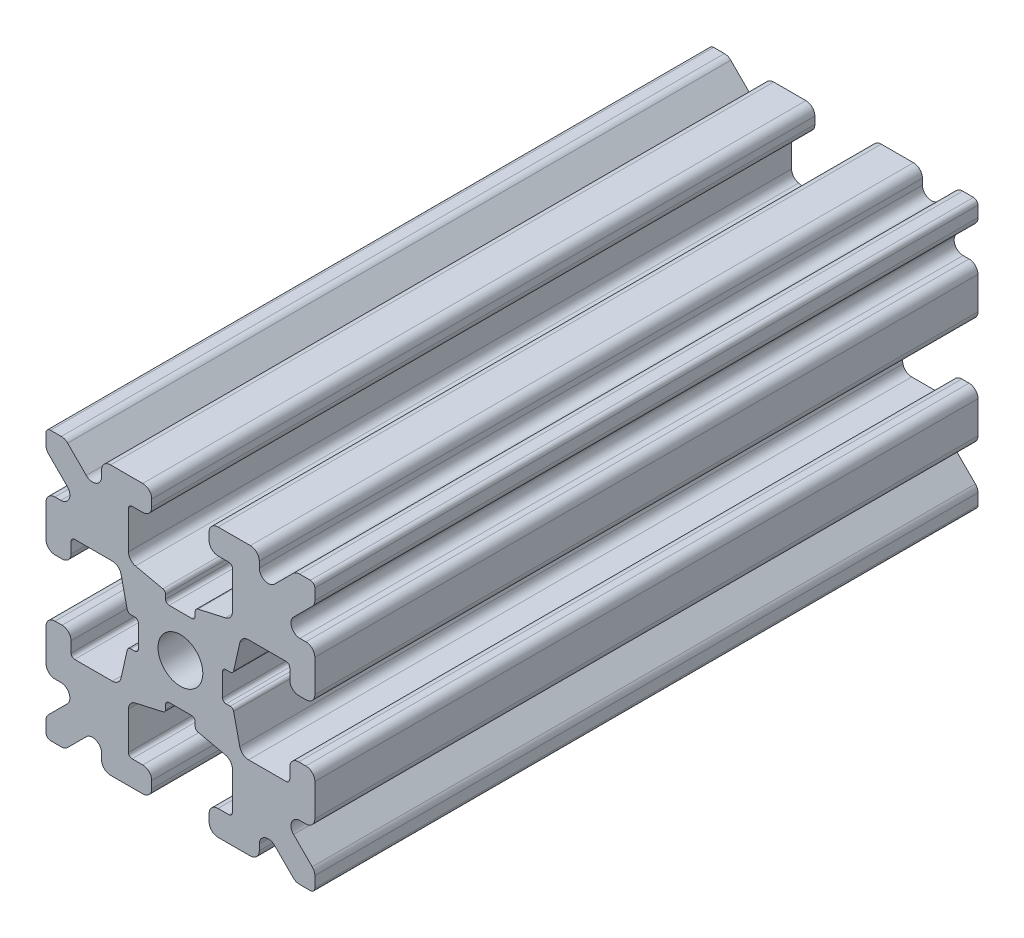
from build123d import *

# Parameters (mm, degrees)
SKETCH1_W           = 15
SKETCH1_H           = 15
SKETCH1_R           = 1.25
BOSS_EXTRUDE1_DEPTH = 18.5
FILLET1_R           = 0.25
CUT_EXTRUDE1_DEPTH  = 38
CUT_EXTRUDE3_DEPTH  = 38
FILLET3_R           = 0.5
FILLET4_R           = 0.5
FILLET5_R           = 3
FILLET6_R           = 0.2
CUT_EXTRUDE4_DEPTH  = 38
FILLET8_R           = 0.5
SKETCH6_W           = 5.1529354
SKETCH6_H           = 1.651
SKETCH6_W_2         = 1.651
SKETCH6_H_2         = 5.1529354
CUT_EXTRUDE5_DEPTH  = 38
FILLET10_R          = 0.2


with BuildPart() as part:
    # Sketch1 → Boss-Extrude1 (new body, symmetric)
    with BuildSketch(Plane.XY):
        Rectangle(SKETCH1_W, SKETCH1_H)
        Circle(SKETCH1_R, mode=Mode.SUBTRACT)
    extrude(amount=BOSS_EXTRUDE1_DEPTH, both=True)

    # Fillet1
    fillet1_edges = [part.edges().sort_by_distance(p)[0] for p in [
        (7.5, -7.5, 0),
        (-7.5, -7.5, 0),
        (-7.5, 7.5, 0),
        (7.5, 7.5, 0),
    ]]
    fillet(fillet1_edges, radius=FILLET1_R)

    # Sketch2 → Cut-Extrude1 (cut, through all)
    with BuildSketch(Plane.XY.offset(18.5)):
        Polygon((-7.5, 1.6), (-6.1, 1.6), (-6.1, 2.9), (-3.4, 2.9), (-3.4, -2.9), (-6.1, -2.9), (-6.1, -1.6), (-7.5, -1.6), align=None)
        Polygon((2.9, 6.1), (1.6, 6.1), (1.6, 7.5), (-1.6, 7.5), (-1.6, 6.1), (-2.9, 6.1), (-2.9, 3.4), (2.9, 3.4), align=None)
        Polygon((-1.6, -7.5), (-1.6, -6.1), (-2.9, -6.1), (-2.9, -3.4), (2.9, -3.4), (2.9, -6.1), (1.6, -6.1), (1.6, -7.5), align=None)
        Polygon((6.1, -2.9), (6.1, -1.6), (7.5, -1.6), (7.5, 1.6), (6.1, 1.6), (6.1, 2.9), (3.4, 2.9), (3.4, -2.9), align=None)
    extrude(amount=-CUT_EXTRUDE1_DEPTH, mode=Mode.SUBTRACT)

    # Sketch4 → Cut-Extrude3 (cut, through all)
    with BuildSketch(Plane.XY.offset(18.5)):
        Polygon((-3.4, 2.9), (-2.75, 0), (-3.4, -2.9), align=None)
        Polygon((-2.9, 3.4), (0, 2.75), (2.9, 3.4), align=None)
        Polygon((3.4, 2.9), (2.75, 0), (3.4, -2.9), align=None)
        Polygon((-2.9, -3.4), (0, -2.75), (2.9, -3.4), align=None)
    extrude(amount=-CUT_EXTRUDE3_DEPTH, mode=Mode.SUBTRACT)

    # Fillet3
    fillet3_edges = [part.edges().sort_by_distance(p)[0] for p in [
        (1.6, -7.5, 0),
        (-1.6, -7.5, 0),
        (-1.6, -6.1, 0),
        (1.6, -6.1, 0),
        (6.1, 1.6, 0),
        (7.5, 1.6, 0),
        (7.5, -1.6, 0),
        (6.1, -1.6, 0),
        (-7.5, -1.6, 0),
        (-7.5, 1.6, 0),
        (-6.1, 1.6, 0),
        (-6.1, -1.6, 0),
        (-1.6, 6.1, 0),
        (-1.6, 7.5, 0),
        (1.6, 7.5, 0),
        (1.6, 6.1, 0),
    ]]
    fillet(fillet3_edges, radius=FILLET3_R)

    # Fillet4
    fillet4_edges = [part.edges().sort_by_distance(p)[0] for p in [
        (-2.9, -3.4, 0),
        (2.9, -3.4, 0),
        (3.4, -2.9, 0),
        (3.4, 2.9, 0),
        (-3.4, 2.9, 0),
        (-3.4, -2.9, 0),
        (2.9, 3.4, 0),
        (-2.9, 3.4, 0),
    ]]
    fillet(fillet4_edges, radius=FILLET4_R)

    # Fillet5
    fillet5_edges = [part.edges().sort_by_distance(p)[0] for p in [
        (-2.75, 0, 0),
        (0, 2.75, 0),
        (2.75, 0, 0),
        (0, -2.75, 0),
    ]]
    fillet(fillet5_edges, radius=FILLET5_R)

    # Fillet6
    fillet6_edges = [part.edges().sort_by_distance(p)[0] for p in [
        (-2.9, -6.1, 0),
        (2.9, -6.1, 0),
        (6.1, -2.9, 0),
        (6.1, 2.9, 0),
        (-6.1, 2.9, 0),
        (-6.1, -2.9, 0),
        (2.9, 6.1, 0),
        (-2.9, 6.1, 0),
    ]]
    fillet(fillet6_edges, radius=FILLET6_R)

    # Sketch5 → Cut-Extrude4 (cut, through all)
    with BuildSketch(Plane.XY.offset(18.5)):
        Polygon((-7.5, 6.439339828), (-5.460660172, 4.4), (-7.5, 4.4), align=None)
        Polygon((-6.439339828, 7.5), (-4.4, 5.460660172), (-4.4, 7.5), align=None)
        Polygon((4.4, 7.5), (6.439339828, 7.5), (4.4, 5.460660172), align=None)
        Polygon((7.5, 6.439339828), (7.5, 4.4), (5.460660172, 4.4), align=None)
        Polygon((7.5, -6.439339828), (5.460660172, -4.4), (7.5, -4.4), align=None)
        Polygon((6.439339828, -7.5), (4.4, -5.460660172), (4.4, -7.5), align=None)
        Polygon((-4.4, -7.5), (-6.439339828, -7.5), (-4.4, -5.460660172), align=None)
        Polygon((-7.5, -6.439339828), (-7.5, -4.4), (-5.460660172, -4.4), align=None)
    extrude(amount=-CUT_EXTRUDE4_DEPTH, mode=Mode.SUBTRACT)

    # Fillet8
    fillet8_edges = [part.edges().sort_by_distance(p)[0] for p in [
        (-7.5, 4.4, 0),
        (-7.5, 6.439339828, 0),
        (-5.460660172, 4.4, 0),
        (7.5, -4.4, 0),
        (7.5, -6.439339828, 0),
        (5.460660172, -4.4, 0),
        (5.460660172, 4.4, 0),
        (7.5, 6.439339828, 0),
        (7.5, 4.4, 0),
        (-4.4, 7.5, 0),
        (-4.4, 5.460660172, 0),
        (-6.439339828, 7.5, 0),
        (-5.460660172, -4.4, 0),
        (-7.5, -6.439339828, 0),
        (-7.5, -4.4, 0),
        (4.4, 5.460660172, 0),
        (4.4, 7.5, 0),
        (6.439339828, 7.5, 0),
        (6.439339828, -7.5, 0),
        (4.4, -7.5, 0),
        (4.4, -5.460660172, 0),
        (-6.439339828, -7.5, 0),
        (-4.4, -5.460660172, 0),
        (-4.4, -7.5, 0),
    ]]
    fillet(fillet8_edges, radius=FILLET8_R)

    # Sketch6 → Cut-Extrude5 (cut, through all)
    with BuildSketch(Plane.XY.offset(18.5)):
        with Locations((4.9235323, 0)):
            Rectangle(SKETCH6_W, SKETCH6_H)
        with Locations((0, -4.9235323)):
            Rectangle(SKETCH6_W_2, SKETCH6_H_2)
        with Locations((-4.9235323, 0)):
            Rectangle(SKETCH6_W, SKETCH6_H)
        with Locations((0, 4.9235323)):
            Rectangle(SKETCH6_W_2, SKETCH6_H_2)
    extrude(amount=-CUT_EXTRUDE5_DEPTH, mode=Mode.SUBTRACT)

    # Fillet10
    fillet10_edges = [part.edges().sort_by_distance(p)[0] for p in [
        (0.8255, -2.935025862, 0),
        (-0.8255, -2.935025862, 0),
        (0.8255, -2.3470646, 0),
        (-0.8255, -2.3470646, 0),
        (2.935025862, 0.8255, 0),
        (2.935025862, -0.8255, 0),
        (2.3470646, 0.8255, 0),
        (2.3470646, -0.8255, 0),
        (-2.935025862, -0.8255, 0),
        (-2.935025862, 0.8255, 0),
        (-2.3470646, -0.8255, 0),
        (-2.3470646, 0.8255, 0),
        (-0.8255, 2.935025862, 0),
        (0.8255, 2.935025862, 0),
        (-0.8255, 2.3470646, 0),
        (0.8255, 2.3470646, 0),
    ]]
    fillet(fillet10_edges, radius=FILLET10_R)


solid = part.part
